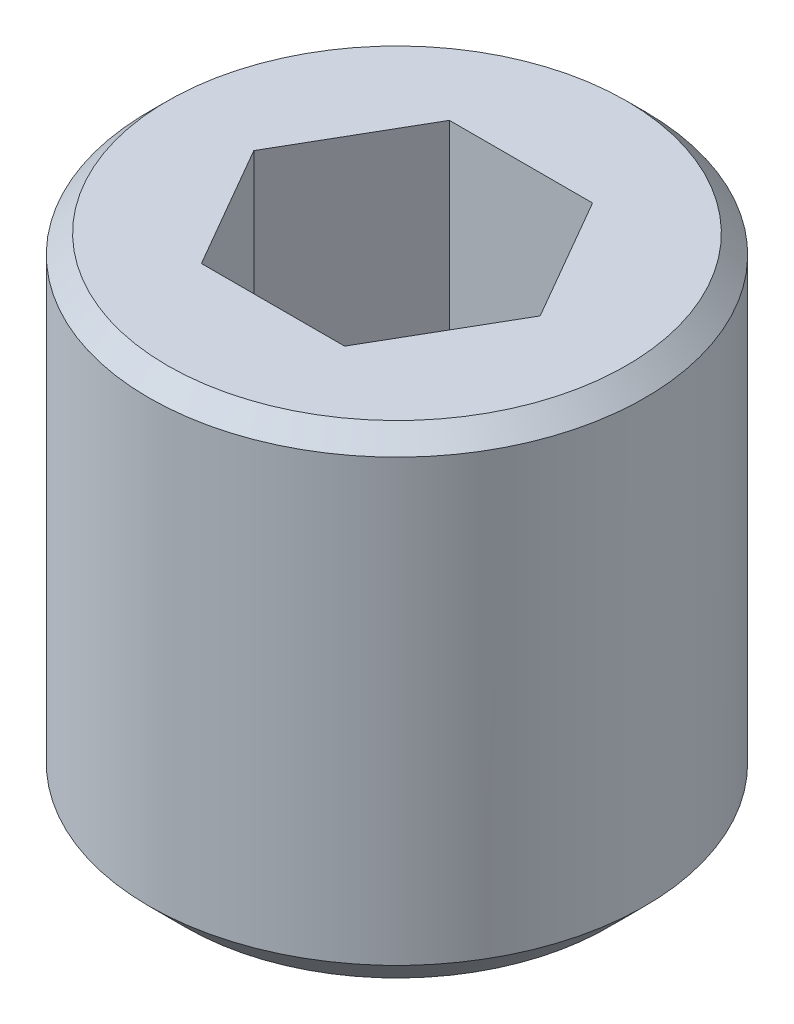
from build123d import *

# Parameters (mm, degrees)
CROQUIS1_W            = 2
CROQUIS1_H            = 4
CORTAR_EXTRUIR2_DEPTH = 2
CHAFL_N3_SIZE         = 0.3
CHAFL_N4_SIZE         = 0.15


with BuildPart() as part:
    # Croquis1 → Revolución1 (revolve)
    with BuildSketch(Plane.XY):
        with Locations((1, -2)):
            Rectangle(CROQUIS1_W, CROQUIS1_H)
    revolve(axis=Axis((0, 0, 0), (0, -1, 0)))

    # Croquis3 → Cortar-Extruir2 (cut)
    with BuildSketch(Plane(origin=(0, 0, 0), x_dir=(1, 0, 0), z_dir=(0, 1, 0))):
        Polygon((-0.577350269, 1), (-1.154700538, 0), (-0.577350269, -1), (0.577350269, -1), (1.154700538, 0), (0.577350269, 1), align=None)
    extrude(amount=-CORTAR_EXTRUIR2_DEPTH, mode=Mode.SUBTRACT)

    # Chaflán3
    chafl_n3_edges = [part.edges().sort_by_distance(p)[0] for p in [
        (-2, -4, 0),
    ]]
    chamfer(chafl_n3_edges, length=CHAFL_N3_SIZE)

    # Chaflán4
    chafl_n4_edges = [part.edges().sort_by_distance(p)[0] for p in [
        (-2, 0, 0),
    ]]
    chamfer(chafl_n4_edges, length=CHAFL_N4_SIZE)


solid = part.part
